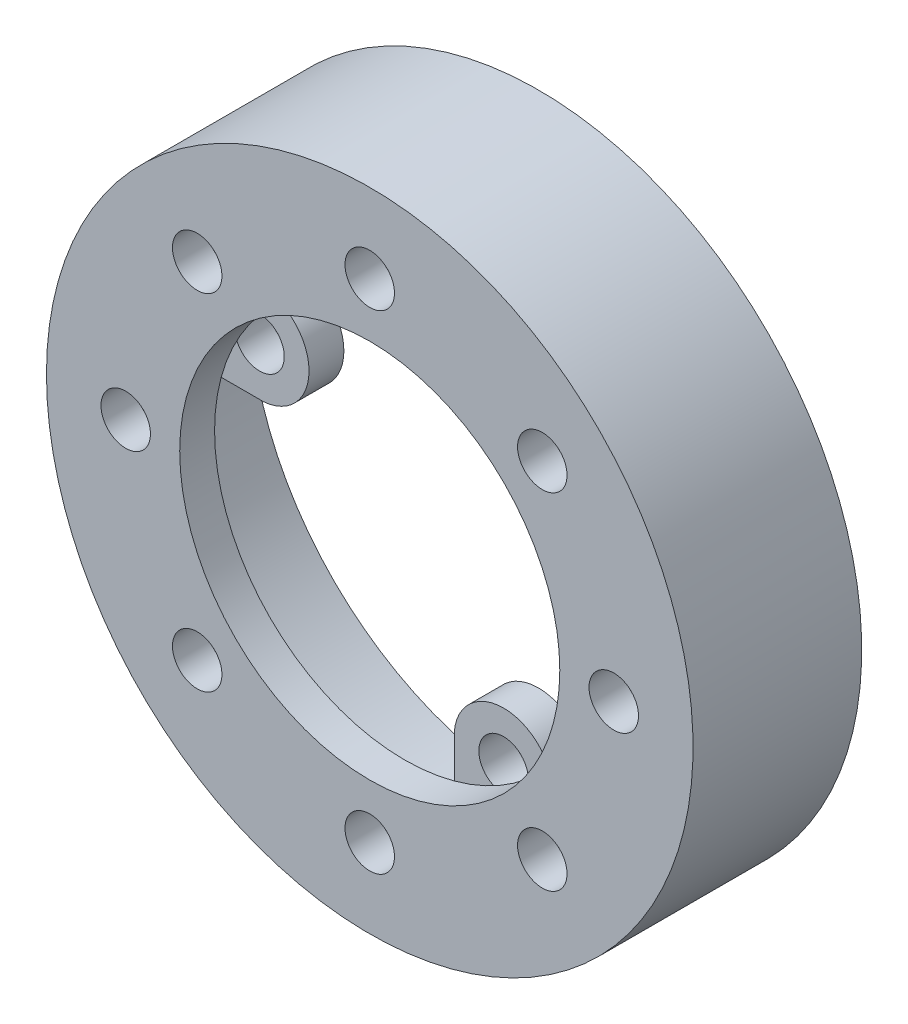
from build123d import *

# Parameters (mm, degrees)
SKETCH2_R           = 5.588
CUT_EXTRUDE1_DEPTH  = 8.874
SKETCH3_R           = 5.588
BOSS_EXTRUDE2_DEPTH = 7.874


with BuildPart() as part:
    # Sketch1 → Revolve1 (revolve)
    with BuildSketch(Plane(origin=(0, 0, 0), x_dir=(1, 0, 0), z_dir=(0, 1, 0))):
        Polygon((73.025, 0), (73.025, 7.874), (73.025, 38.1), (65.278, 38.1), (65.278, 7.874), (42.926, 7.874), (42.926, 0), align=None)
    revolve(axis=Axis((0, 0, -38.1), (0, 0, 1)))

    # Sketch2 → Cut-Extrude1 (cut, through all)
    with BuildSketch(Plane(origin=(0, 0, -7.874), x_dir=(-1, 0, 0), z_dir=(0, 0, -1))):
        with Locations((0, 55.118)):
            Circle(SKETCH2_R)
        with Locations((38.974311565, 38.974311565)):
            Circle(SKETCH2_R)
        with Locations((55.118, 0)):
            Circle(SKETCH2_R)
        with Locations((38.974311565, -38.974311565)):
            Circle(SKETCH2_R)
        with Locations((0, -55.118)):
            Circle(SKETCH2_R)
        with Locations((-38.974311565, -38.974311565)):
            Circle(SKETCH2_R)
        with Locations((-55.118, 0)):
            Circle(SKETCH2_R)
        with Locations((-38.974311565, 38.974311565)):
            Circle(SKETCH2_R)
    extrude(amount=-CUT_EXTRUDE1_DEPTH, mode=Mode.SUBTRACT)

    # Sketch3 → Boss-Extrude2 (add)
    with BuildSketch(Plane(origin=(0, 0, -38.1), x_dir=(-1, 0, 0), z_dir=(0, 0, -1))):
        with BuildLine():
            Line((11.134976442, 54.161299611), (11.134976442, 64.321299611))
            ThreePointArc((11.134976442, 64.321299611), (0, 65.278), (-11.134976442, 64.321299611))
            Line((-11.134976442, 64.321299611), (-11.134976442, 54.161299611))
            ThreePointArc((-11.134976442, 54.161299611), (0, 43.942), (11.134976442, 54.161299611))
        make_face()
        with Locations((0, 55.118)):
            Circle(SKETCH3_R, mode=Mode.SUBTRACT)
        with BuildLine():
            Line((54.161299611, 11.134976442), (64.321299611, 11.134976442))
            ThreePointArc((64.321299611, 11.134976442), (65.278, 0), (64.321299611, -11.134976442))
            Line((64.321299611, -11.134976442), (54.161299611, -11.134976442))
            ThreePointArc((54.161299611, -11.134976442), (43.942, 0), (54.161299611, 11.134976442))
        make_face()
        with Locations((55.118, 0)):
            Circle(SKETCH3_R, mode=Mode.SUBTRACT)
        with BuildLine():
            Line((11.134976442, -54.161299611), (11.134976442, -64.321299611))
            ThreePointArc((11.134976442, -64.321299611), (0, -65.278), (-11.134976442, -64.321299611))
            Line((-11.134976442, -64.321299611), (-11.134976442, -54.161299611))
            ThreePointArc((-11.134976442, -54.161299611), (0, -43.942), (11.134976442, -54.161299611))
        make_face()
        with Locations((0, -55.118)):
            Circle(SKETCH3_R, mode=Mode.SUBTRACT)
        with BuildLine():
            Line((-54.161299611, -11.134976442), (-64.321299611, -11.134976442))
            ThreePointArc((-64.321299611, -11.134976442), (-65.278, 0), (-64.321299611, 11.134976442))
            Line((-64.321299611, 11.134976442), (-54.161299611, 11.134976442))
            ThreePointArc((-54.161299611, 11.134976442), (-43.942, 0), (-54.161299611, -11.134976442))
        make_face()
        with Locations((-55.118, 0)):
            Circle(SKETCH3_R, mode=Mode.SUBTRACT)
    extrude(amount=-BOSS_EXTRUDE2_DEPTH)


solid = part.part
